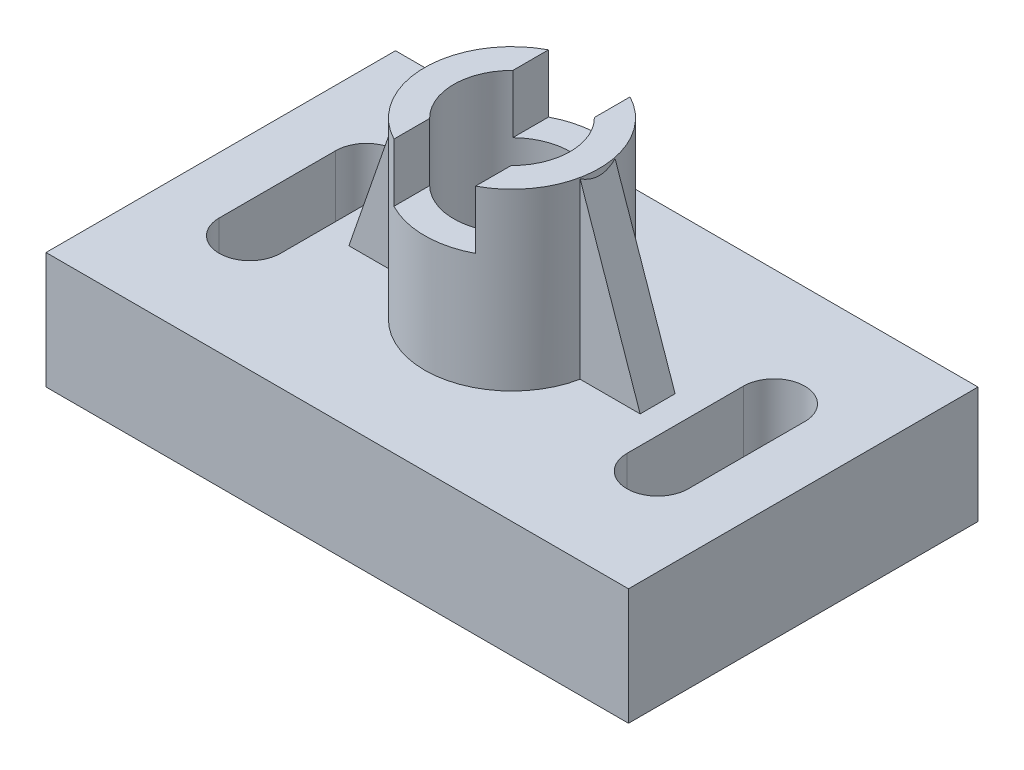
from build123d import *

# Parameters (mm, degrees)
SKETCH1_W           = 100
SKETCH1_H           = 60
BOSS_EXTRUDE2_DEPTH = 20
SKETCH2_R           = 15
SKETCH2_R_2         = 10
BOSS_EXTRUDE3_DEPTH = 30
SKETCH3_W           = 14
SKETCH3_H           = 35.201995264
CUT_EXTRUDE1_DEPTH  = 10
RIB4_REACH          = 78.811
SKETCH19_WALL_W     = 186.230224572
SKETCH19_WALL_H     = 6


with BuildPart() as part:
    # Sketch1 → Boss-Extrude2 (new body)
    with BuildSketch(Plane(origin=(0, 0, 0), x_dir=(1, 0, 0), z_dir=(0, 1, 0))):
        Rectangle(SKETCH1_W, SKETCH1_H)
        with BuildLine():
            ThreePointArc((-44.951219512, -10), (-35, -19.951219512), (-25.048780488, -10))
            Line((-25.048780488, -10), (-25.048780488, 10))
            ThreePointArc((-25.048780488, 10), (-35, 19.951219512), (-44.951219512, 10))
            Line((-44.951219512, 10), (-44.951219512, -10))
        make_face(mode=Mode.SUBTRACT)
        with BuildLine():
            Line((44.951219512, 10), (44.951219512, -10))
            ThreePointArc((44.951219512, -10), (35, -19.951219512), (25.048780488, -10))
            Line((25.048780488, -10), (25.048780488, 10))
            ThreePointArc((25.048780488, 10), (35, 19.951219512), (44.951219512, 10))
        make_face(mode=Mode.SUBTRACT)
        with BuildLine():
            Line((-44.951219512, 10), (-44.951219512, -10))
            ThreePointArc((-44.951219512, -10), (-35, -19.951219512), (-25.048780488, -10))
            Line((-25.048780488, -10), (-25.048780488, 10))
            ThreePointArc((-25.048780488, 10), (-35, 19.951219512), (-44.951219512, 10))
        make_face()
        with BuildLine():
            ThreePointArc((-40.268292683, -10), (-35, -15.268292683), (-29.731707317, -10))
            Line((-29.731707317, -10), (-29.731707317, 10))
            ThreePointArc((-29.731707317, 10), (-35, 15.268292683), (-40.268292683, 10))
            Line((-40.268292683, 10), (-40.268292683, -10))
        make_face(mode=Mode.SUBTRACT)
        with BuildLine():
            ThreePointArc((44.951219512, -10), (35, -19.951219512), (25.048780488, -10))
            Line((25.048780488, -10), (25.048780488, 10))
            ThreePointArc((25.048780488, 10), (35, 19.951219512), (44.951219512, 10))
            Line((44.951219512, 10), (44.951219512, -10))
        make_face()
        with BuildLine():
            Line((40.268292683, 10), (40.268292683, -10))
            ThreePointArc((40.268292683, -10), (35, -15.268292683), (29.731707317, -10))
            Line((29.731707317, -10), (29.731707317, 10))
            ThreePointArc((29.731707317, 10), (35, 15.268292683), (40.268292683, 10))
        make_face(mode=Mode.SUBTRACT)
    extrude(amount=BOSS_EXTRUDE2_DEPTH)

    # Sketch2 → Boss-Extrude3 (add)
    with BuildSketch(Plane(origin=(0, 20, 0), x_dir=(1, 0, 0), z_dir=(0, 1, 0))):
        with Locations(Location((0, 0, 0), (0, 0, 270))):
            Circle(SKETCH2_R)
        with Locations(Location((0, 0, 0), (0, 0, 270))):
            Circle(SKETCH2_R_2, mode=Mode.SUBTRACT)
    extrude(amount=BOSS_EXTRUDE3_DEPTH)

    # Sketch3 → Cut-Extrude1 (cut)
    with BuildSketch(Plane(origin=(0, 50, 0), x_dir=(1, 0, 0), z_dir=(0, 1, 0))):
        Rectangle(SKETCH3_W, SKETCH3_H)
    extrude(amount=-CUT_EXTRUDE1_DEPTH, mode=Mode.SUBTRACT)

    # Sketch19 wall → Rib4 (add, up to next)
    with BuildSketch(Plane(origin=(20, 34.463811754, 0), x_dir=(0.32671934012, -0.945121406377, 0), z_dir=(0.945121406377, 0.32671934012, 0)), mode=Mode.PRIVATE) as rib4_sk1:
        Rectangle(SKETCH19_WALL_W, SKETCH19_WALL_H)
    rib4_tool1 = extrude(rib4_sk1.sketch, amount=-RIB4_REACH, mode=Mode.PRIVATE) - part.part
    rib4 = rib4_tool1.solids().sort_by_distance((20, 34.463811754, 0))[0]
    add(rib4)

    # Mirror2: Rib4 across plane
    add(rib4.mirror(Plane(origin=(0, 0, 0), x_dir=(0, 0, 1), z_dir=(1, 0, 0))))


solid = part.part
